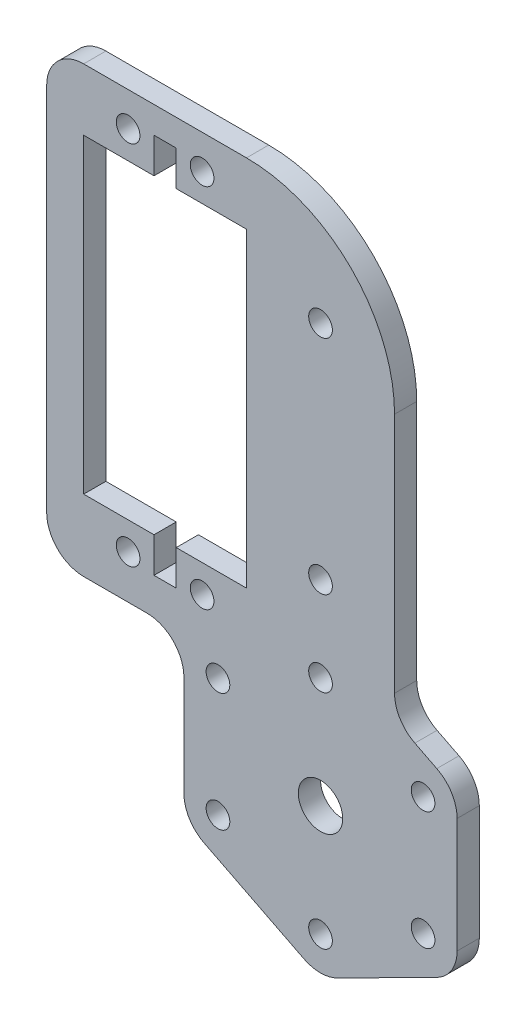
from build123d import *

# Parameters (mm, degrees)
ESBO_O1_R                = 1.6
ESBO_O1_R_2              = 3
RESSALTO_EXTRUS_O1_DEPTH = 3


with BuildPart() as part:
    # Esboço1 → Ressalto-extrusão1 (new body)
    with BuildSketch(Plane(origin=(0, 0, -13), x_dir=(-1, 0, 0), z_dir=(0, 0, -1))):
        with BuildLine():
            Line((11, 29.35), (-11, 29.35))
            ThreePointArc((-11, 29.35), (-25.142135624, 23.492135624), (-31, 9.35))
            Line((-31, 9.35), (-31, -23.298998166))
            ThreePointArc((-31, -23.298998166), (-31.741318167, -25.918851033), (-33.745451618, -27.76184609))
            Line((-33.745451618, -27.76184609), (-36.710953382, -29.259962834))
            ThreePointArc((-36.710953382, -29.259962834), (-38.715086833, -31.102957891), (-39.456405, -33.722810758))
            Line((-39.456405, -33.722810758), (-39.456405, -49.230667326))
            ThreePointArc((-39.456405, -49.230667326), (-38.715086833, -51.850520194), (-36.710953382, -53.693515251))
            Line((-36.710953382, -53.693515251), (-23.254548382, -60.491442635))
            ThreePointArc((-23.254548382, -60.491442635), (-21, -61.028594711), (-18.745451618, -60.491442635))
            Line((-18.745451618, -60.491442635), (-5.289046618, -53.693515251))
            ThreePointArc((-5.289046618, -53.693515251), (-3.284913167, -51.850520194), (-2.543595, -49.230667326))
            Line((-2.543595, -49.230667326), (-2.543595, -35.646914307))
            ThreePointArc((-2.543595, -35.646914307), (-1.079128906, -32.111380402), (2.456405, -30.646914307))
            Line((2.456405, -30.646914307), (11, -30.646914307))
            ThreePointArc((11, -30.646914307), (14.535533906, -29.182448213), (16, -25.646914307))
            Line((16, -25.646914307), (16, 24.35))
            ThreePointArc((16, 24.35), (14.535533906, 27.885533906), (11, 29.35))
        make_face()
        with Locations((-5, -24.75)):
            Circle(ESBO_O1_R, mode=Mode.SUBTRACT)
        with Locations((-5, 24.75)):
            Circle(ESBO_O1_R, mode=Mode.SUBTRACT)
        with Locations((5, -24.75)):
            Circle(ESBO_O1_R, mode=Mode.SUBTRACT)
        with Locations((5, 24.75)):
            Circle(ESBO_O1_R, mode=Mode.SUBTRACT)
        with Locations((-21, 15)):
            Circle(ESBO_O1_R, mode=Mode.SUBTRACT)
        with Locations((-21, -15)):
            Circle(ESBO_O1_R, mode=Mode.SUBTRACT)
        with Locations((-7.143595, -33.476739042)):
            Circle(ESBO_O1_R, mode=Mode.SUBTRACT)
        with Locations((-7.143595, -49.476739042)):
            Circle(ESBO_O1_R, mode=Mode.SUBTRACT)
        with Locations((-21, -26.476739042)):
            Circle(ESBO_O1_R, mode=Mode.SUBTRACT)
        with Locations((-21, -56.476739042)):
            Circle(ESBO_O1_R, mode=Mode.SUBTRACT)
        with Locations((-21, -41.476739042)):
            Circle(ESBO_O1_R_2, mode=Mode.SUBTRACT)
        with Locations((-34.856405, -33.476739042)):
            Circle(ESBO_O1_R, mode=Mode.SUBTRACT)
        with Locations((-34.856405, -49.476739042)):
            Circle(ESBO_O1_R, mode=Mode.SUBTRACT)
        Polygon((-1.5, -21), (-11, -21), (-11, 21), (-1.5, 21), (-1.5, 25.75), (1.5, 25.75), (1.5, 21), (11, 21), (11, -21), (1.5, -21), (1.5, -25.75), (-1.5, -25.75), align=None, mode=Mode.SUBTRACT)
    extrude(amount=-RESSALTO_EXTRUS_O1_DEPTH)


solid = part.part
